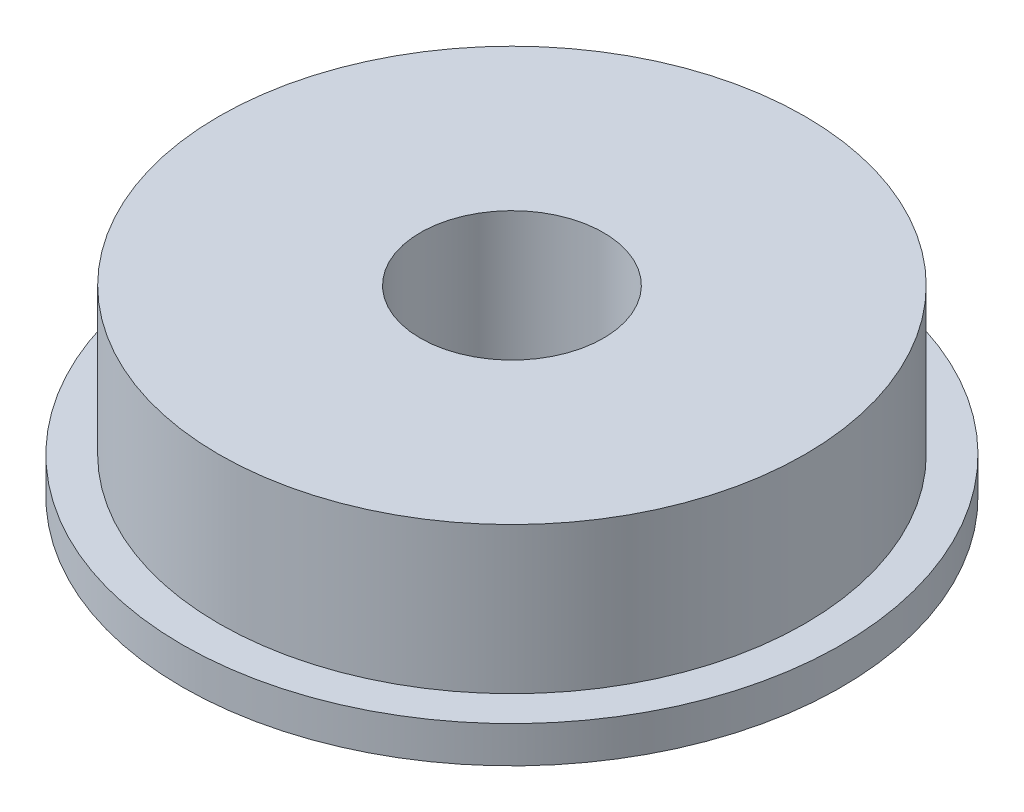
from build123d import *

# Parameters (mm, degrees)
SKETCH1_R           = 72
BOSS_EXTRUDE1_DEPTH = 8
SKETCH2_R           = 64
BOSS_EXTRUDE2_DEPTH = 32
SKETCH3_R           = 20
CUT_EXTRUDE1_DEPTH  = 41
SCALE1_SCALE        = 0.125


with BuildPart() as part:
    # Sketch1 → Boss-Extrude1 (new body)
    with BuildSketch(Plane(origin=(0, 0, 0), x_dir=(1, 0, 0), z_dir=(0, 1, 0))):
        Circle(SKETCH1_R)
    extrude(amount=BOSS_EXTRUDE1_DEPTH)

    # Sketch2 → Boss-Extrude2 (add)
    with BuildSketch(Plane(origin=(0, 8, 0), x_dir=(1, 0, 0), z_dir=(0, 1, 0))):
        Circle(SKETCH2_R)
    extrude(amount=BOSS_EXTRUDE2_DEPTH)

    # Sketch3 → Cut-Extrude1 (cut, through all)
    with BuildSketch(Plane(origin=(0, 40, 0), x_dir=(1, 0, 0), z_dir=(0, 1, 0))):
        Circle(SKETCH3_R)
    extrude(amount=-CUT_EXTRUDE1_DEPTH, mode=Mode.SUBTRACT)


with BuildPart() as part_1:
    # Scale1: scaled about (0, 19.110384301, 0)
    add(part.part.scale(SCALE1_SCALE).moved(Location((0, 16.721586263, 0))))


solid = part_1.part
